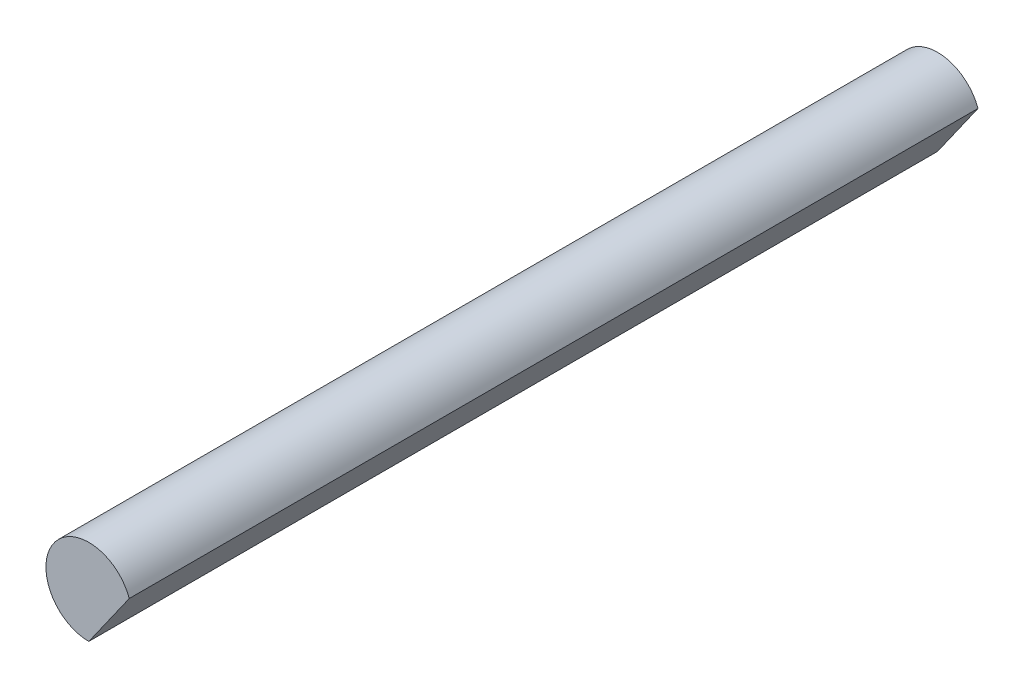
from build123d import *

# Parameters (mm, degrees)
BOSS_EXTRUDE1_DEPTH = 29.66


with BuildPart() as part:
    # Sketch1 → Boss-Extrude1 (new body)
    with BuildSketch(Plane.XY):
        with BuildLine():
            Line((-0.00170223, -1.499999034), (1.411890351, 0.506523085))
            ThreePointArc((1.411890351, 0.506523085), (-1.22625054, 0.86389213), (-0.00170223, -1.499999034))
        make_face()
    extrude(amount=BOSS_EXTRUDE1_DEPTH)


solid = part.part
